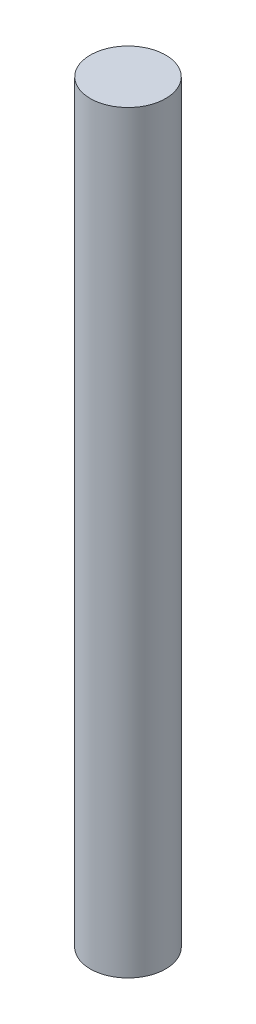
from build123d import *

# Parameters (mm, degrees)
SKETCH1_R           = 10
BOSS_EXTRUDE1_DEPTH = 100


with BuildPart() as part:
    # Sketch1 → Boss-Extrude1 (new body, symmetric)
    with BuildSketch(Plane(origin=(0, 0, 0), x_dir=(1, 0, 0), z_dir=(0, 1, 0))):
        Circle(SKETCH1_R)
    extrude(amount=BOSS_EXTRUDE1_DEPTH, both=True)


solid = part.part
